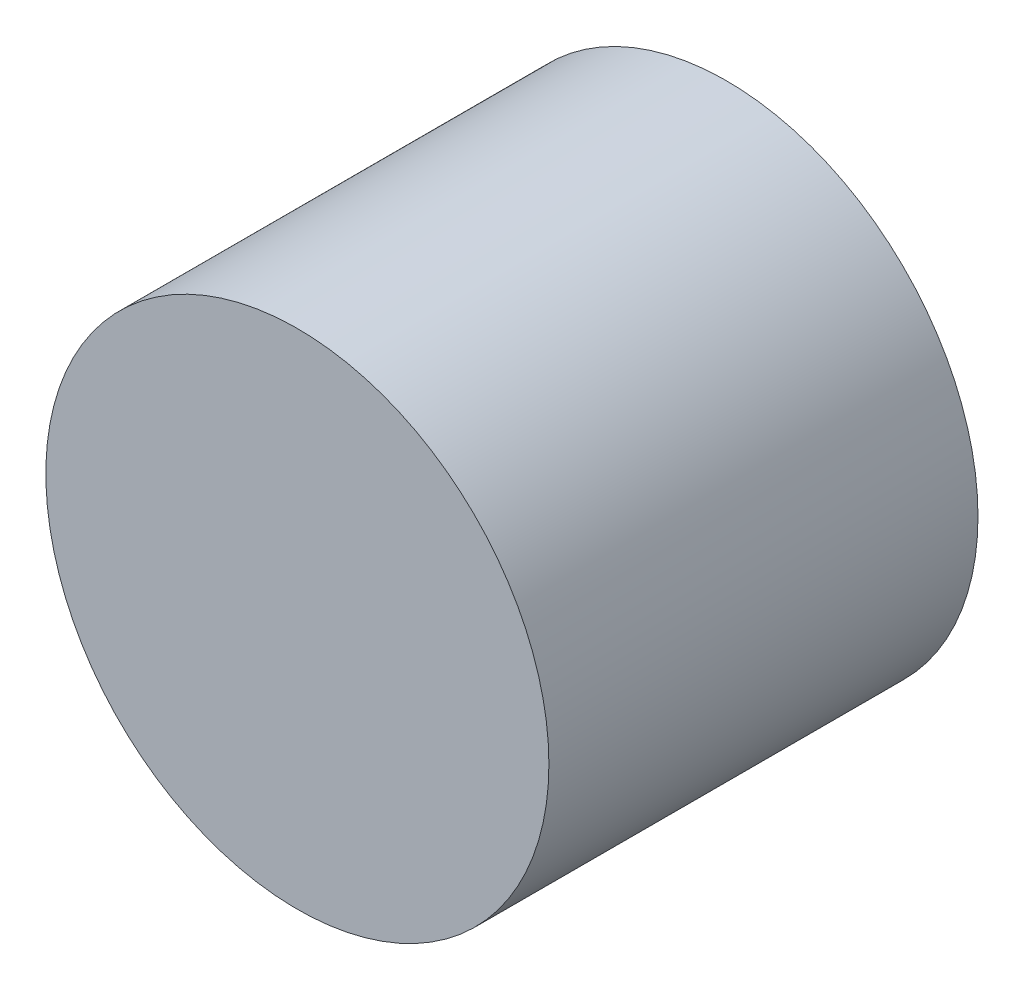
from build123d import *

# Parameters (mm, degrees)
SKETCH1_R           = 8.5
BOSS_EXTRUDE1_DEPTH = 14.5


with BuildPart() as part:
    # Sketch1 → Boss-Extrude1 (new body)
    with BuildSketch(Plane.XY):
        Circle(SKETCH1_R)
    extrude(amount=BOSS_EXTRUDE1_DEPTH)


solid = part.part
